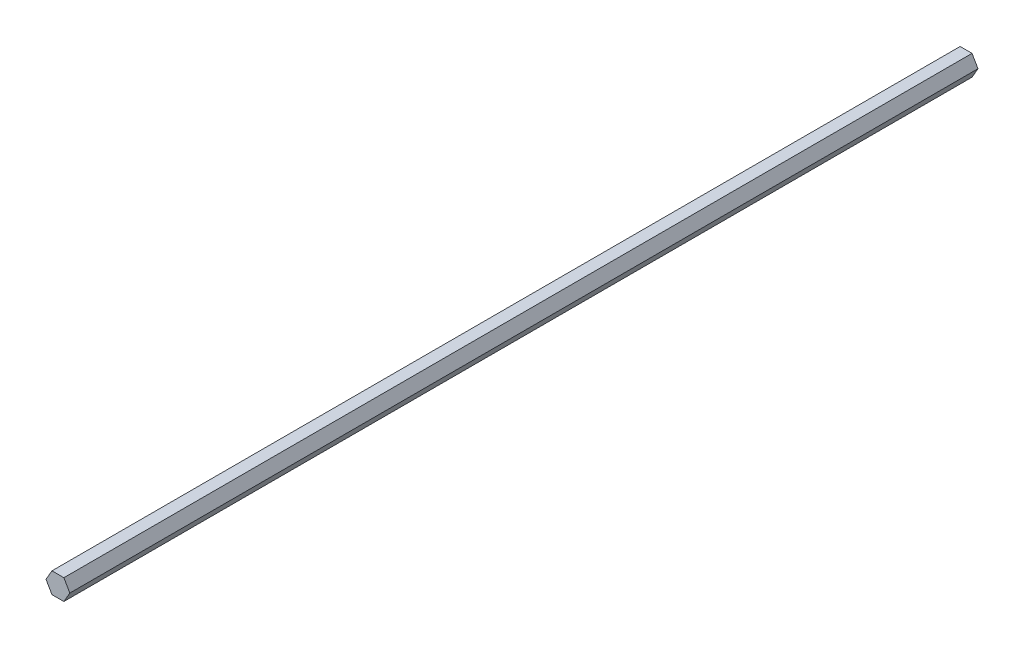
from build123d import *

# Parameters (mm, degrees)
BOSS_EXTRUDE1_DEPTH = 558.8


with BuildPart() as part:
    # Sketch1 → Boss-Extrude1 (new body)
    with BuildSketch(Plane.XY):
        Polygon((3.666174209, -6.35), (7.332348419, 0), (3.666174209, 6.35), (-3.666174209, 6.35), (-7.332348419, 0), (-3.666174209, -6.35), align=None)
    extrude(amount=BOSS_EXTRUDE1_DEPTH)


solid = part.part
